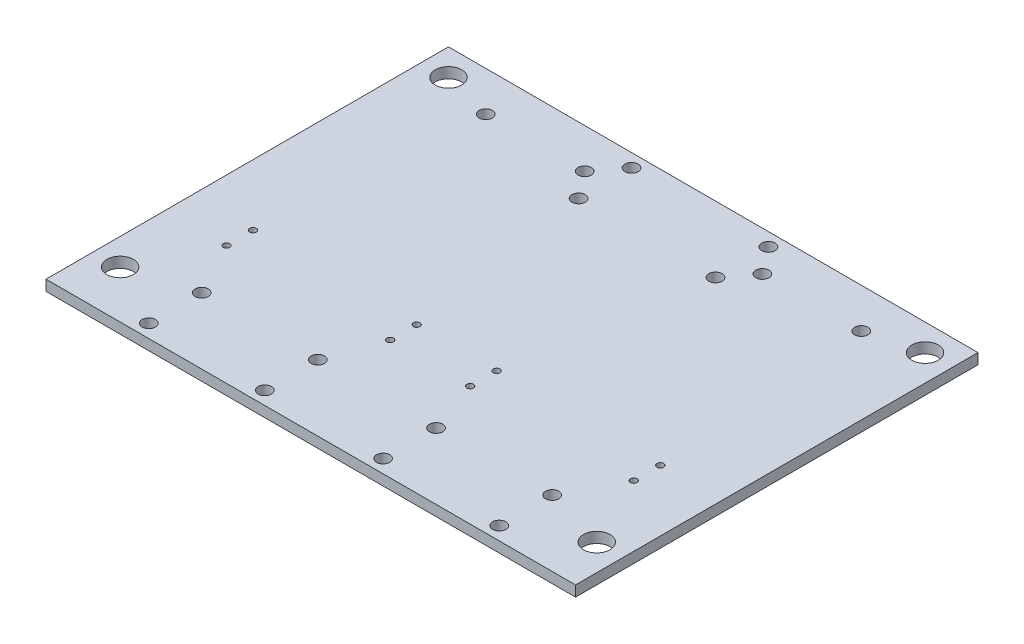
from build123d import *

# Parameters (mm, degrees)
SKETCH1_W           = 254
SKETCH1_H           = 5.08
BOSS_EXTRUDE1_DEPTH = 203.2
SKETCH3_R           = 6.35
CUT_EXTRUDE1_DEPTH  = 6.08
SKETCH5_R           = 1.5875
CUT_EXTRUDE2_DEPTH  = 152.4
SKETCH12_R          = 3.175
CUT_EXTRUDE7_DEPTH  = 6.08
SKETCH14_R          = 3.175
CUT_EXTRUDE8_DEPTH  = 5.08
CUT_EXTRUDE9_REACH  = 7.08
SKETCH15_W          = 254
SKETCH15_H          = 10.16
SKETCH16_R          = 3.175
CUT_EXTRUDE10_DEPTH = 6.08
SKETCH19_R          = 3.175
CUT_EXTRUDE11_DEPTH = 5.08


with BuildPart() as part:
    # Sketch1 → Boss-Extrude1 (new body)
    with BuildSketch(Plane.XY):
        Rectangle(SKETCH1_W, SKETCH1_H)
    extrude(amount=BOSS_EXTRUDE1_DEPTH)

    # Sketch3 → Cut-Extrude1 (cut, through all)
    with BuildSketch(Plane(origin=(0, 2.54, 0), x_dir=(1, 0, 0), z_dir=(0, 1, 0))):
        with Locations((-114.3, -22.86)):
            Circle(SKETCH3_R)
        with Locations((-114.3, -180.34)):
            Circle(SKETCH3_R)
        with Locations((114.3, -22.86)):
            Circle(SKETCH3_R)
        with Locations((114.3, -180.34)):
            Circle(SKETCH3_R)
    extrude(amount=-CUT_EXTRUDE1_DEPTH, mode=Mode.SUBTRACT)

    # Sketch5 → Cut-Extrude2 (cut)
    with BuildSketch(Plane(origin=(0, 2.54, 0), x_dir=(1, 0, 0), z_dir=(0, 1, 0))):
        with Locations((97.63, -133.2)):
            Circle(SKETCH5_R)
        with Locations((97.63, -145.9)):
            Circle(SKETCH5_R)
        with Locations((-19.21, -133.2)):
            Circle(SKETCH5_R)
        with Locations((-19.21, -145.9)):
            Circle(SKETCH5_R)
        with Locations((-97.696, -133.2)):
            Circle(SKETCH5_R)
        with Locations((-97.696, -145.9)):
            Circle(SKETCH5_R)
        with Locations((19.144, -133.2)):
            Circle(SKETCH5_R)
        with Locations((19.144, -145.9)):
            Circle(SKETCH5_R)
    extrude(amount=-CUT_EXTRUDE2_DEPTH, mode=Mode.SUBTRACT)

    # Sketch12 → Cut-Extrude7 (cut, through all)
    with BuildSketch(Plane(origin=(0, 2.54, 0), x_dir=(1, 0, 0), z_dir=(0, 1, 0))):
        with Locations((-90.0557, -29.21)):
            Circle(SKETCH12_R)
        with Locations((-42.6212, -29.21)):
            Circle(SKETCH12_R)
    cut_extrude7 = extrude(amount=-CUT_EXTRUDE7_DEPTH, mode=Mode.SUBTRACT)

    # Sketch14 → Cut-Extrude8 (cut)
    with BuildSketch(Plane(origin=(0, 2.54, 0), x_dir=(1, 0, 0), z_dir=(0, 1, 0))):
        with Locations((-32.832800096, -16.51)):
            Circle(SKETCH14_R)
        with Locations((-32.832800096, -41.91)):
            Circle(SKETCH14_R)
    cut_extrude8 = extrude(amount=-CUT_EXTRUDE8_DEPTH, mode=Mode.SUBTRACT)

    # Mirror1: Cut-Extrude7, Cut-Extrude8 across plane
    add(cut_extrude7.mirror(Plane(origin=(0, 0, 0), x_dir=(0, 0, 1), z_dir=(1, 0, 0))), mode=Mode.SUBTRACT)
    add(cut_extrude8.mirror(Plane(origin=(0, 0, 0), x_dir=(0, 0, 1), z_dir=(1, 0, 0))), mode=Mode.SUBTRACT)

    # Sketch15 → Cut-Extrude9 (cut, up to next)
    with BuildSketch(Plane(origin=(0, 2.54, 0), x_dir=(1, 0, 0), z_dir=(0, 1, 0)), mode=Mode.PRIVATE) as cut_extrude9_sk1:
        with Locations((0, -5.08)):
            Rectangle(SKETCH15_W, SKETCH15_H)
    cut_extrude9_tool1 = extrude(cut_extrude9_sk1.sketch, amount=-CUT_EXTRUDE9_REACH, mode=Mode.PRIVATE) & part.part
    add(cut_extrude9_tool1.solids().sort_by_distance((0, 2.54, 5.08))[0], mode=Mode.SUBTRACT)

    # Sketch16 → Cut-Extrude10 (cut, through all)
    with BuildSketch(Plane(origin=(0, 2.54, 0), x_dir=(1, 0, 0), z_dir=(0, 1, 0))):
        with Locations((84.0486, -196.85)):
            Circle(SKETCH16_R)
        with Locations((84.0486, -171.45)):
            Circle(SKETCH16_R)
    cut_extrude10 = extrude(amount=-CUT_EXTRUDE10_DEPTH, mode=Mode.SUBTRACT)

    # Mirror2: Cut-Extrude10 across plane
    add(cut_extrude10.mirror(Plane(origin=(0, 0, 0), x_dir=(0, 0, 1), z_dir=(1, 0, 0))), mode=Mode.SUBTRACT)

    # Sketch19 → Cut-Extrude11 (cut)
    with BuildSketch(Plane(origin=(0, 2.54, 0), x_dir=(1, 0, 0), z_dir=(0, 1, 0))):
        with Locations((-28.357399872, -171.45)):
            Circle(SKETCH19_R)
        with Locations((-28.357399872, -196.85)):
            Circle(SKETCH19_R)
    cut_extrude11 = extrude(amount=-CUT_EXTRUDE11_DEPTH, mode=Mode.SUBTRACT)

    # Mirror3: Cut-Extrude11 across plane
    add(cut_extrude11.mirror(Plane(origin=(0, 0, 0), x_dir=(0, 0, 1), z_dir=(1, 0, 0))), mode=Mode.SUBTRACT)


solid = part.part
